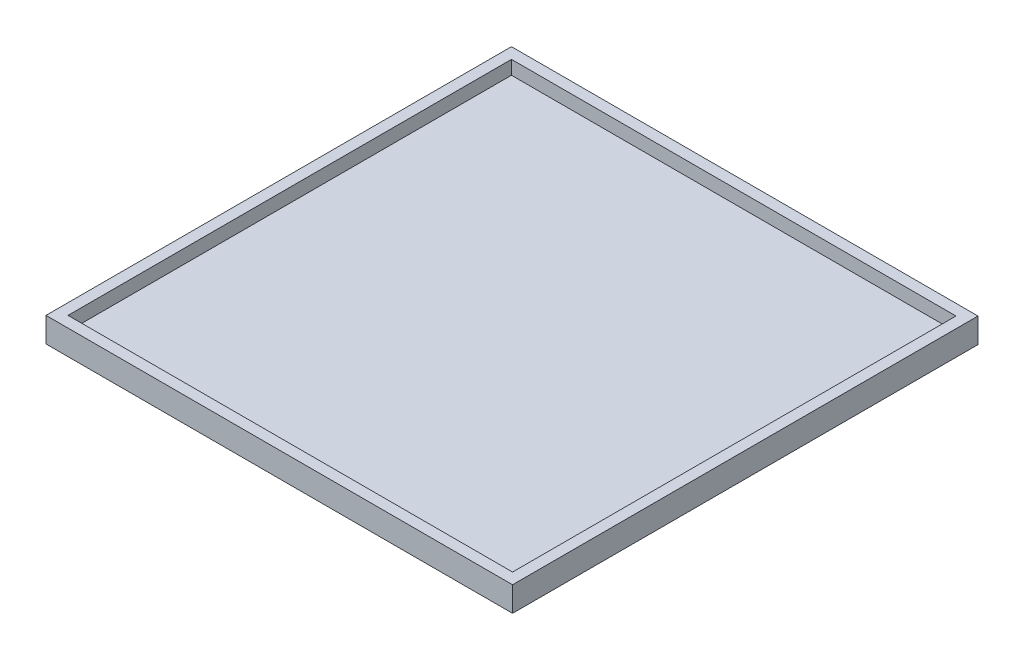
from build123d import *

# Parameters (mm, degrees)
SKETCH1_W           = 1025.399999996
SKETCH1_H           = 1022.859999996
BOSS_EXTRUDE1_DEPTH = 31.75
SHELL1_T            = 25.4


with BuildPart() as part:
    # Sketch1 → Boss-Extrude1 (new body)
    with BuildSketch(Plane(origin=(0, 0, 0), x_dir=(1, 0, 0), z_dir=(0, 1, 0))):
        Rectangle(SKETCH1_W, SKETCH1_H)
    extrude(amount=BOSS_EXTRUDE1_DEPTH)

    # Shell1
    shell1_openings = [part.faces().sort_by_distance(p)[0] for p in [
        (0, 31.75, 0),
    ]]
    offset(amount=SHELL1_T, openings=shell1_openings, kind=Kind.INTERSECTION)


solid = part.part
